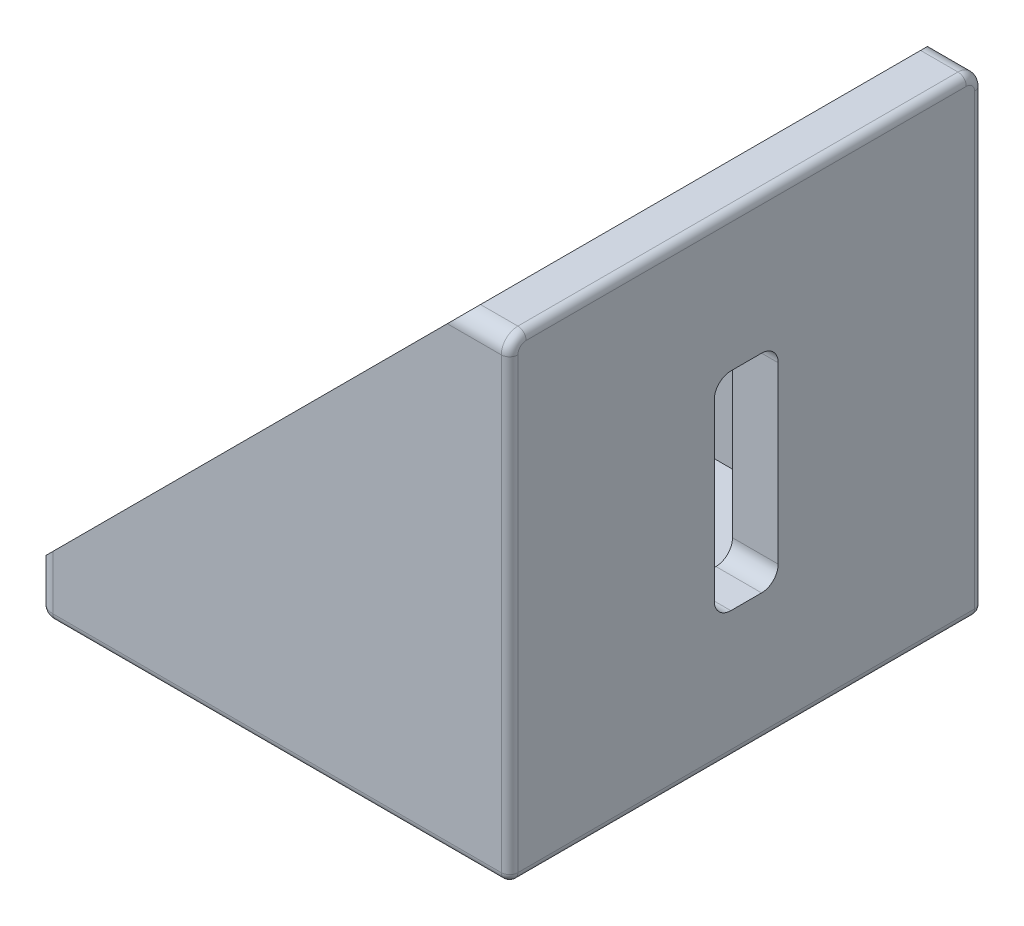
from build123d import *

# Parameters (mm, degrees)
BOSS_EXTRUDE1_DEPTH = 28.5
CUT_EXTRUDE1_DEPTH  = 23
SKETCH3_W           = 7.7
SKETCH3_H           = 25
CUT_EXTRUDE2_DEPTH  = 6.5
SKETCH4_W           = 25
SKETCH4_H           = 7.7
CUT_EXTRUDE3_DEPTH  = 6.5
FILLET1_R           = 2
FILLET2_R           = 2
FILLET3_R           = 1


with BuildPart() as part:
    # Sketch1 → Boss-Extrude1 (new body, symmetric)
    with BuildSketch(Plane.XY):
        Polygon((-57, 0), (0, 0), (0, 57), (-5.5, 57), (-57, 5.5), align=None)
    extrude(amount=BOSS_EXTRUDE1_DEPTH, both=True)

    # Sketch2 → Cut-Extrude1 (cut, symmetric)
    with BuildSketch(Plane.XY):
        Polygon((-5.5, 57), (-5.5, 5.5), (-57, 5.5), align=None)
    extrude(amount=CUT_EXTRUDE1_DEPTH, both=True, mode=Mode.SUBTRACT)

    # Sketch3 → Cut-Extrude2 (cut, through all)
    with BuildSketch(Plane.ZY.offset(5.5)):
        with Locations((0, 28)):
            Rectangle(SKETCH3_W, SKETCH3_H)
    extrude(amount=-CUT_EXTRUDE2_DEPTH, mode=Mode.SUBTRACT)

    # Sketch4 → Cut-Extrude3 (cut, through all)
    with BuildSketch(Plane(origin=(0, 5.5, 0), x_dir=(1, 0, 0), z_dir=(0, 1, 0))):
        with Locations((-25, 0)):
            Rectangle(SKETCH4_W, SKETCH4_H)
    extrude(amount=-CUT_EXTRUDE3_DEPTH, mode=Mode.SUBTRACT)

    # Fillet1
    fillet1_edges = [part.edges().sort_by_distance(p)[0] for p in [
        (-2.75, 57, 28.5),
        (-57, 2.75, 28.5),
        (-2.75, 57, -28.5),
        (-57, 2.75, -28.5),
    ]]
    fillet(fillet1_edges, radius=FILLET1_R)

    # Fillet2
    fillet2_edges = [part.edges().sort_by_distance(p)[0] for p in [
        (-2.75, 40.5, 3.85),
        (-2.75, 15.5, 3.85),
        (-2.75, 15.5, -3.85),
        (-2.75, 40.5, -3.85),
        (-12.5, 2.75, -3.85),
        (-12.5, 2.75, 3.85),
        (-37.5, 2.75, 3.85),
        (-37.5, 2.75, -3.85),
    ]]
    fillet(fillet2_edges, radius=FILLET2_R)

    # Fillet3
    fillet3_edges = [part.edges().sort_by_distance(p)[0] for p in [
        (0, 27.5, 28.5),
        (-57, 0, 0),
        (-27.5, 0, -28.5),
        (-27.5, 0, 28.5),
        (-56.414213562, 0, 27.914213562),
        (-56.414213562, 0, -27.914213562),
        (0, 27.5, -28.5),
        (0, 57, 0),
        (0, 56.414213562, 27.914213562),
        (0, 56.414213562, -27.914213562),
        (0, 0, 0),
    ]]
    fillet(fillet3_edges, radius=FILLET3_R)


solid = part.part
